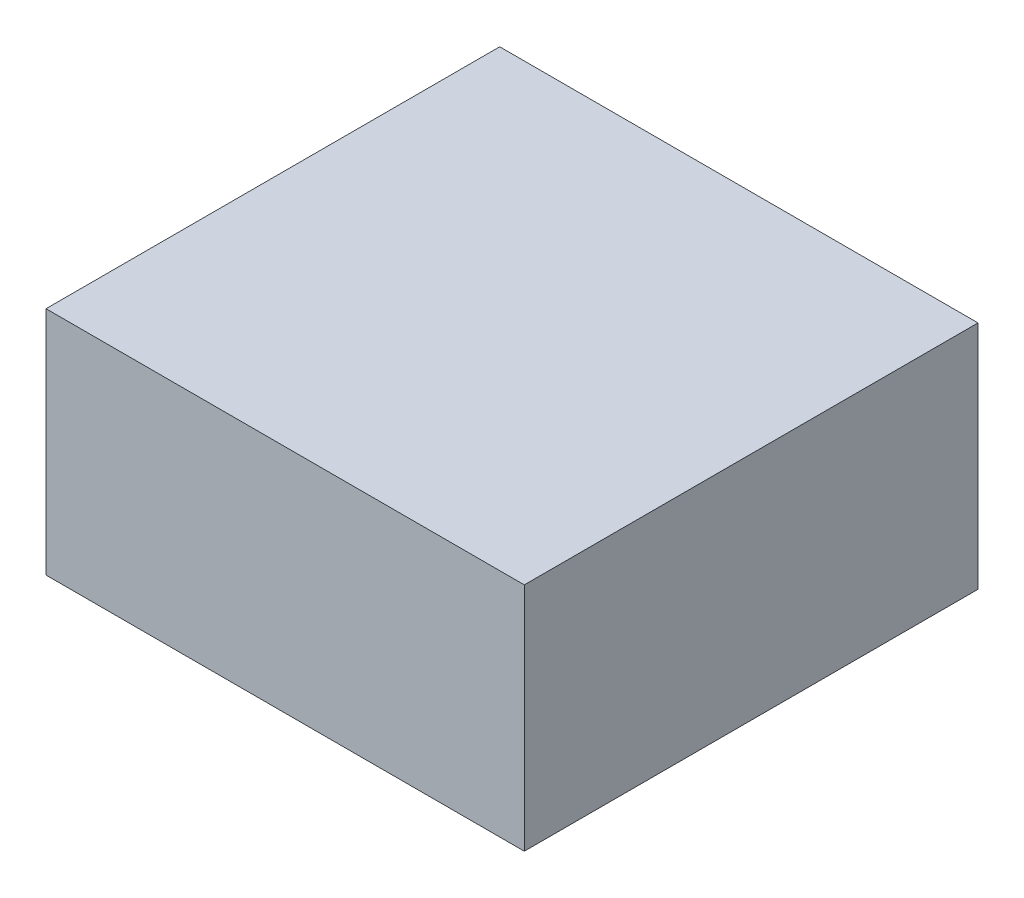
from build123d import *

# Parameters (mm, degrees)
SKETCH1_W           = 78.994
SKETCH1_H           = 38.1
BOSS_EXTRUDE1_DEPTH = 74.93


with BuildPart() as part:
    # Sketch1 → Boss-Extrude1 (new body)
    with BuildSketch(Plane.XY):
        Rectangle(SKETCH1_W, SKETCH1_H)
    extrude(amount=BOSS_EXTRUDE1_DEPTH)


solid = part.part
